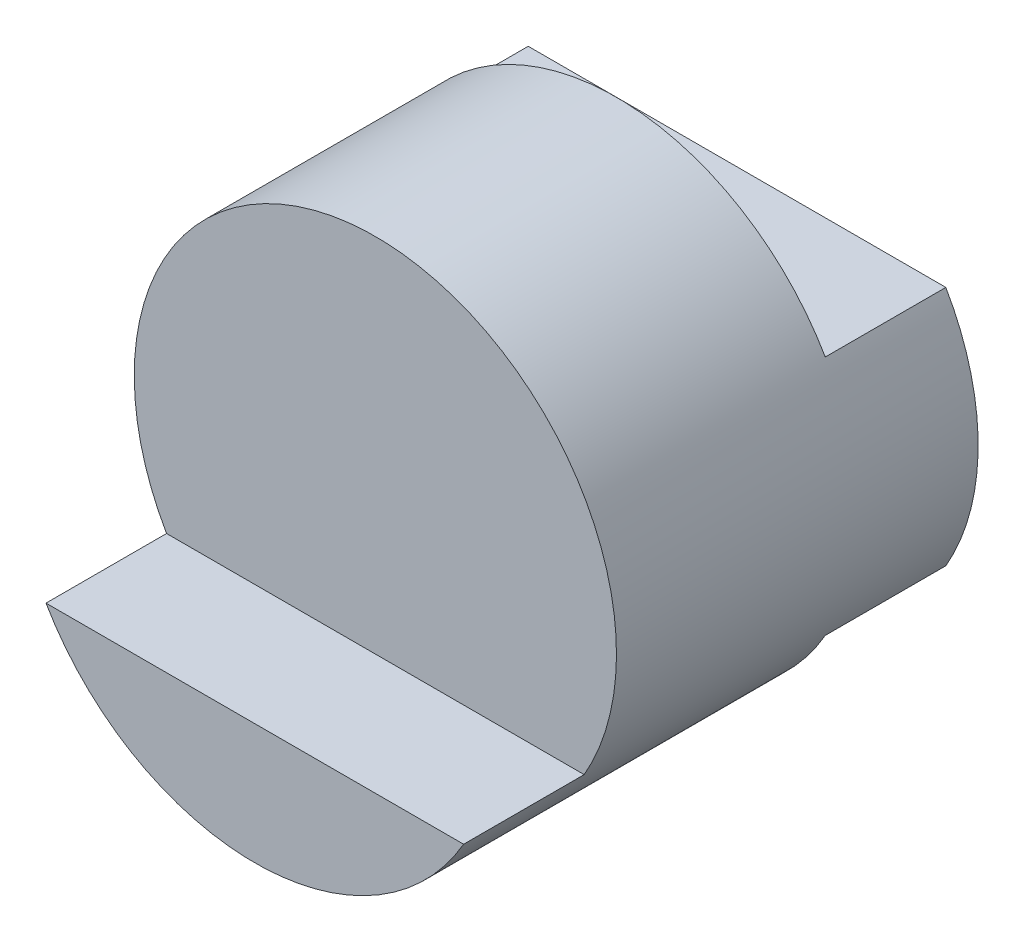
from build123d import *

# Parameters (mm, degrees)
SKETCH1_R           = 2
BOSS_EXTRUDE1_DEPTH = 3
BOSS_EXTRUDE2_DEPTH = 1
CUT_EXTRUDE1_DEPTH  = 1
CUT_EXTRUDE2_DEPTH  = 1


with BuildPart() as part:
    # Sketch1 → Boss-Extrude1 (new body)
    with BuildSketch(Plane.XY):
        Circle(SKETCH1_R)
    extrude(amount=BOSS_EXTRUDE1_DEPTH)

    # Sketch2 → Boss-Extrude2 (add)
    with BuildSketch(Plane.XY.offset(3)):
        with BuildLine():
            Line((-1.732050808, -1), (1.732050808, -1))
            ThreePointArc((1.732050808, -1), (0, -2), (-1.732050808, -1))
        make_face()
    extrude(amount=BOSS_EXTRUDE2_DEPTH)

    # Sketch3 → Cut-Extrude1 (cut)
    with BuildSketch(Plane(origin=(0, 0, 0), x_dir=(-1, 0, 0), z_dir=(0, 0, -1))):
        with BuildLine():
            Line((1.732050808, 1), (-1.732050808, 1))
            ThreePointArc((-1.732050808, 1), (0, 2), (1.732050808, 1))
        make_face()
    extrude(amount=-CUT_EXTRUDE1_DEPTH, mode=Mode.SUBTRACT)

    # Sketch4 → Cut-Extrude2 (cut)
    with BuildSketch(Plane(origin=(0, 0, 0), x_dir=(-1, 0, 0), z_dir=(0, 0, -1))):
        with BuildLine():
            Line((1.732050808, -1), (-1.732050808, -1))
            ThreePointArc((-1.732050808, -1), (0, -2), (1.732050808, -1))
        make_face()
    extrude(amount=-CUT_EXTRUDE2_DEPTH, mode=Mode.SUBTRACT)


solid = part.part
